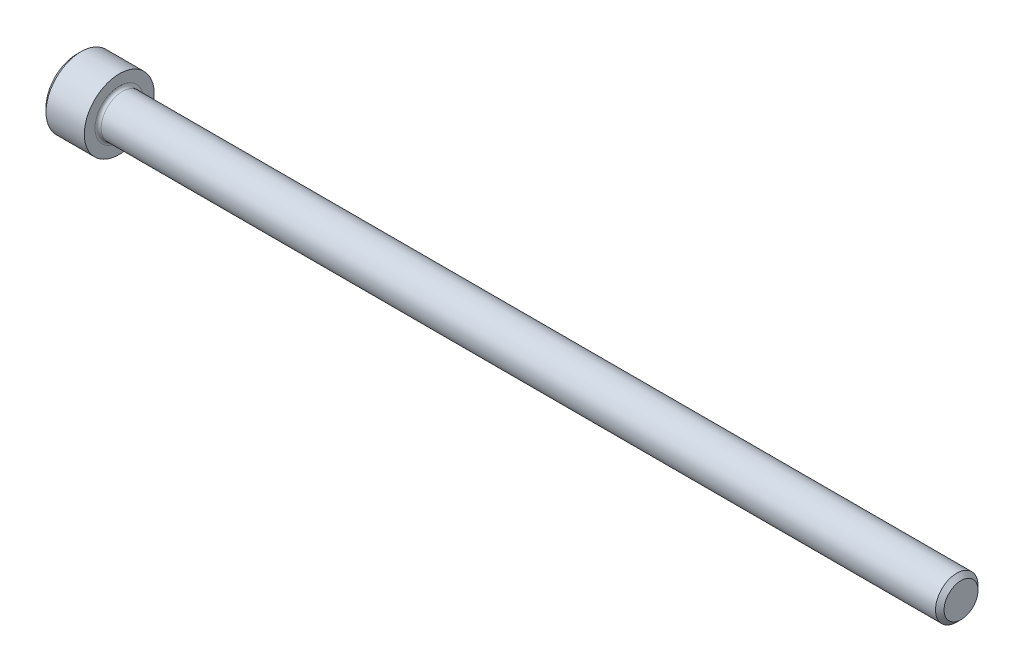
from build123d import *

# Parameters (mm, degrees)
FILLET1_R   = 0.3048
HEX_2_DEPTH = 1.9558


with BuildPart() as part:
    # BodySke → Base-Revolve (revolve)
    with BuildSketch(Plane.XY):
        Polygon((0, 0), (0, 3.0226), (0.4064, 3.429), (4.1656, 3.429), (4.1656, 2.0828), (86.29523, 2.0828), (86.7156, 1.66243), (86.7156, 0), align=None)
    revolve(axis=Axis((-31.75, 0, 0), (1, 0, 0)))

    # Fillet1
    fillet1_edges = [part.edges().sort_by_distance(p)[0] for p in [
        (4.1656, -2.0828, 0),
    ]]
    fillet(fillet1_edges, radius=FILLET1_R)

    # Sketch2 → Hex-PreBroach (revolve, cut)
    with BuildSketch(Plane.XY):
        Polygon((0, 1.778), (1.9558, 1.778), (2.982328779, 0), (0, 0), align=None)
    revolve(axis=Axis((0, 0, 0), (1, 0, 0)), mode=Mode.SUBTRACT)

    # Sketch3 → Hex 2 (cut)
    with BuildSketch(Plane(origin=(0, 0, 0), x_dir=(0, 0.5, 0.866025404), z_dir=(-1, 0, 0))):
        Polygon((1.026528779, 1.778), (-1.026528779, 1.778), (-2.053057557, 0), (-1.026528779, -1.778), (1.026528779, -1.778), (2.053057557, 0), align=None)
    extrude(amount=-HEX_2_DEPTH, mode=Mode.SUBTRACT)


solid = part.part
